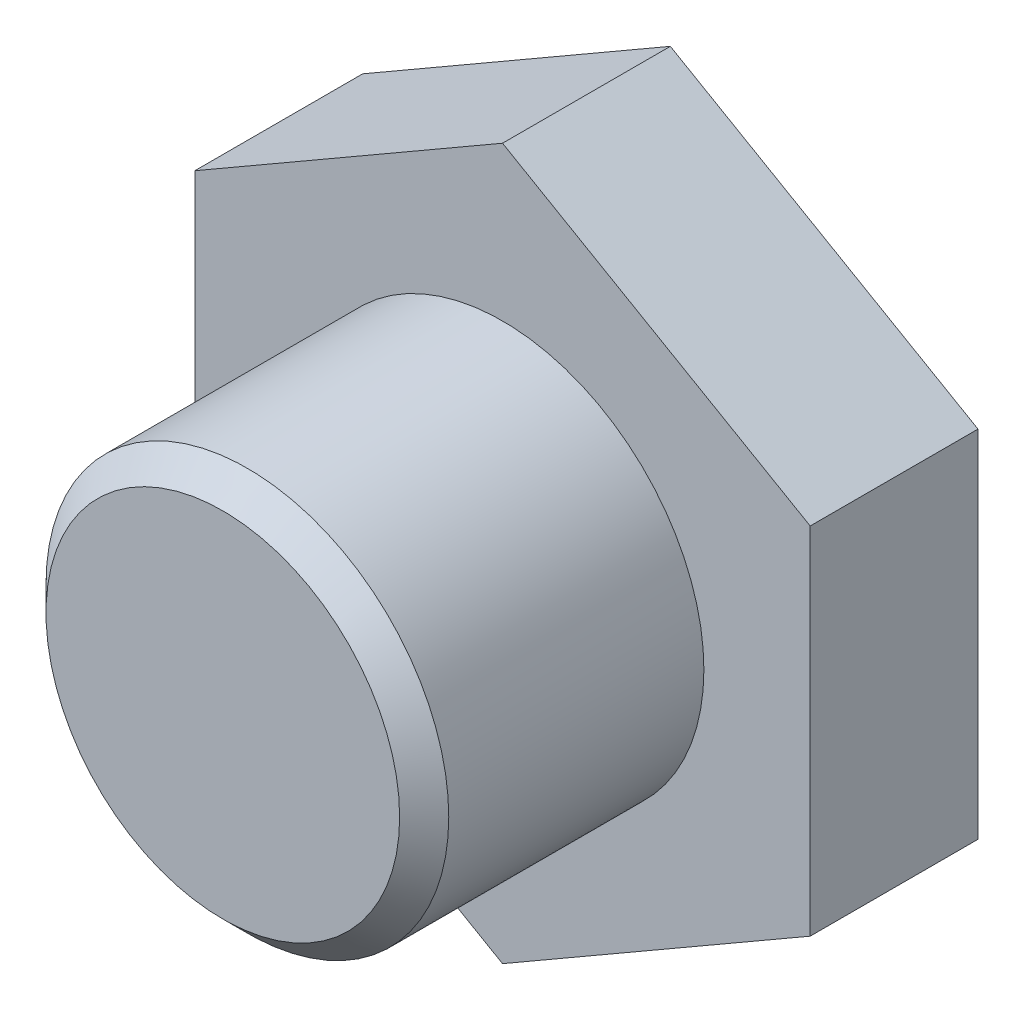
from build123d import *

# Parameters (mm, degrees)
EXTRUDE_1_DEPTH = 15
SKETCH_2_R      = 18
EXTRUDE_2_DEPTH = 25
CHAMFER_1_SIZE  = 2.195


with BuildPart() as part:
    # Эскиз1 → Бобышка-Вытянуть1 (new body)
    with BuildSketch(Plane.XY):
        Polygon((0, 31.754264805), (-27.5, 15.877132403), (-27.5, -15.877132403), (0, -31.754264805), (27.5, -15.877132403), (27.5, 15.877132403), align=None)
    extrude(amount=EXTRUDE_1_DEPTH)

    # Эскиз2 → Бобышка-Вытянуть2 (add)
    with BuildSketch(Plane.XY.offset(15)):
        Circle(SKETCH_2_R)
    extrude(amount=EXTRUDE_2_DEPTH)

    # Фаска1
    chamfer_1_edges = [part.edges().sort_by_distance(p)[0] for p in [
        (-18, 0, 40),
    ]]
    chamfer(chamfer_1_edges, length=CHAMFER_1_SIZE)


solid = part.part
